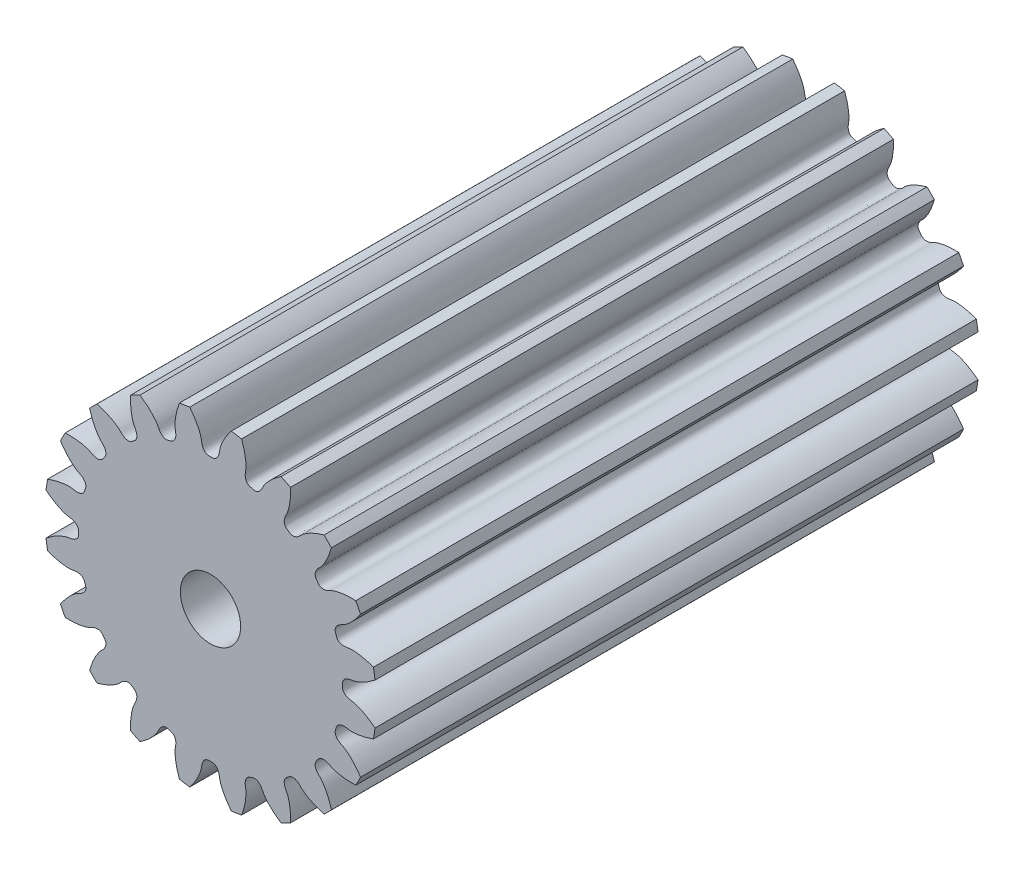
from build123d import *

# Parameters (mm, degrees)
SKETCHREVOLVESPURGEAR1_W       = 20
SKETCHREVOLVESPURGEAR1_H       = 5.499999917
TOOTHEXTRUDECUTSPURGEAR1_DEPTH = 10
PATTERNSPURGEAR1_COUNT         = 20
BOREREVOLVESKETCH_W            = 20
BOREREVOLVESKETCH_H            = 1


with BuildPart() as part:
    # SketchRevolveSpurGear1 → SpurGear1 (revolve)
    with BuildSketch(Plane(origin=(0, 0, 0), x_dir=(0, 0, -1), z_dir=(1, 0, 0))):
        with Locations((0, 2.749999959)):
            Rectangle(SKETCHREVOLVESPURGEAR1_W, SKETCHREVOLVESPURGEAR1_H)
    revolve(axis=Axis((0, 0, 0), (0, 0, -1)))

    # SketchToothSpurGear1 → ToothExtrudeCutSpurGear1 (cut, symmetric)
    with BuildSketch(Plane.XY):
        with BuildLine():
            ThreePointArc((5.479605309, 0.706788324), (5.524999917, 0), (5.479605309, -0.706788324))
            add(Edge.make_bspline(
                [(5.479605309, -0.706788324), (5.435404482, -0.670877372), (5.369307557, -0.620309878), (5.280568529, -0.558889651), (5.218284655, -0.51856898), (5.158633122, -0.482517921), (5.101814762, -0.450532909), (5.048020267, -0.422402065), (4.997429872, -0.397905741), (4.950213056, -0.376816955), (4.906528269, -0.3589018), (4.866522656, -0.343920086), (4.830331878, -0.331625257), (4.79807968, -0.321766639), (4.769878333, -0.31408451), (4.745826516, -0.308326896), (4.726014734, -0.304202955), (4.6830745, -0.296753707), (4.637427165, -0.292743909), (4.589884099, -0.280886123), (4.565199786, -0.273548043), (4.541459249, -0.264988916), (4.518564058, -0.255118714), (4.496419545, -0.243708294), (4.474943599, -0.230444344), (4.454110549, -0.214878544), (4.434031507, -0.196415078), (4.415082677, -0.174339712), (4.398103211, -0.147959142), (4.384426421, -0.116954775), (4.376754303, -0.084451556), (4.373607289, -0.044989712), (4.375891317, 0), (4.373607289, 0.044989712), (4.376754303, 0.084451556), (4.384426421, 0.116954775), (4.398103211, 0.147959142), (4.415082677, 0.174339712), (4.434031507, 0.196415078), (4.454110549, 0.214878544), (4.474943599, 0.230444344), (4.496419545, 0.243708294), (4.518564058, 0.255118714), (4.541459249, 0.264988916), (4.565199786, 0.273548043), (4.589884099, 0.280886123), (4.637427165, 0.292743909), (4.6830745, 0.296753707), (4.726014734, 0.304202955), (4.745826516, 0.308326896), (4.769878333, 0.31408451), (4.79807968, 0.321766639), (4.830331878, 0.331625257), (4.866522656, 0.343920086), (4.906528269, 0.3589018), (4.950213056, 0.376816955), (4.997429872, 0.397905741), (5.048020267, 0.422402065), (5.101814762, 0.450532909), (5.158633122, 0.482517921), (5.218284655, 0.51856898), (5.280568529, 0.558889651), (5.369307557, 0.620309878), (5.435404482, 0.670877372), (5.479605309, 0.706788324)],
                knots=[0, 0, 0, 0, 0.061422842, 0.089709677, 0.116380121, 0.141434175, 0.164871838, 0.186693111, 0.206897994, 0.225486485, 0.242458587, 0.257814298, 0.271553618, 0.283676548, 0.294183087, 0.303073236, 0.310346995, 0.316004363, 0.350076802, 0.359567688, 0.36880314, 0.37784437, 0.386769007, 0.395675631, 0.404688756, 0.413962948, 0.423682731, 0.434051196, 0.445255861, 0.457401439, 0.47041984, 0.481066796, 0.5, 0.518933204, 0.52958016, 0.542598561, 0.554744139, 0.565948804, 0.576317269, 0.586037052, 0.595311244, 0.604324369, 0.613230993, 0.62215563, 0.63119686, 0.640432312, 0.649923198, 0.683995637, 0.689653005, 0.696926764, 0.705816913, 0.716323452, 0.728446382, 0.742185702, 0.757541413, 0.774513515, 0.793102006, 0.813306889, 0.835128162, 0.858565825, 0.883619879, 0.910290323, 0.938577158, 1, 1, 1, 1], degree=3))
        make_face()
    toothextrudecutspurgear1 = extrude(amount=TOOTHEXTRUDECUTSPURGEAR1_DEPTH, both=True, mode=Mode.SUBTRACT)

    # PatternSpurGear1: ToothExtrudeCutSpurGear1 ×20 about axis
    patternspurgear1_axis = Axis((0, 0, 55), (0, 0, -1))
    for i in range(1, PATTERNSPURGEAR1_COUNT):
        add(toothextrudecutspurgear1.rotate(patternspurgear1_axis, i * 360 / PATTERNSPURGEAR1_COUNT), mode=Mode.SUBTRACT)

    # BoreRevolveSketch → BoreRevolveCut (revolve, cut)
    with BuildSketch(Plane(origin=(0, 0, 0), x_dir=(0, 0, -1), z_dir=(1, 0, 0))):
        with Locations((0, 0.5)):
            Rectangle(BOREREVOLVESKETCH_W, BOREREVOLVESKETCH_H)
    revolve(axis=Axis((0, 0, 0), (0, 0, -1)), mode=Mode.SUBTRACT)


solid = part.part
